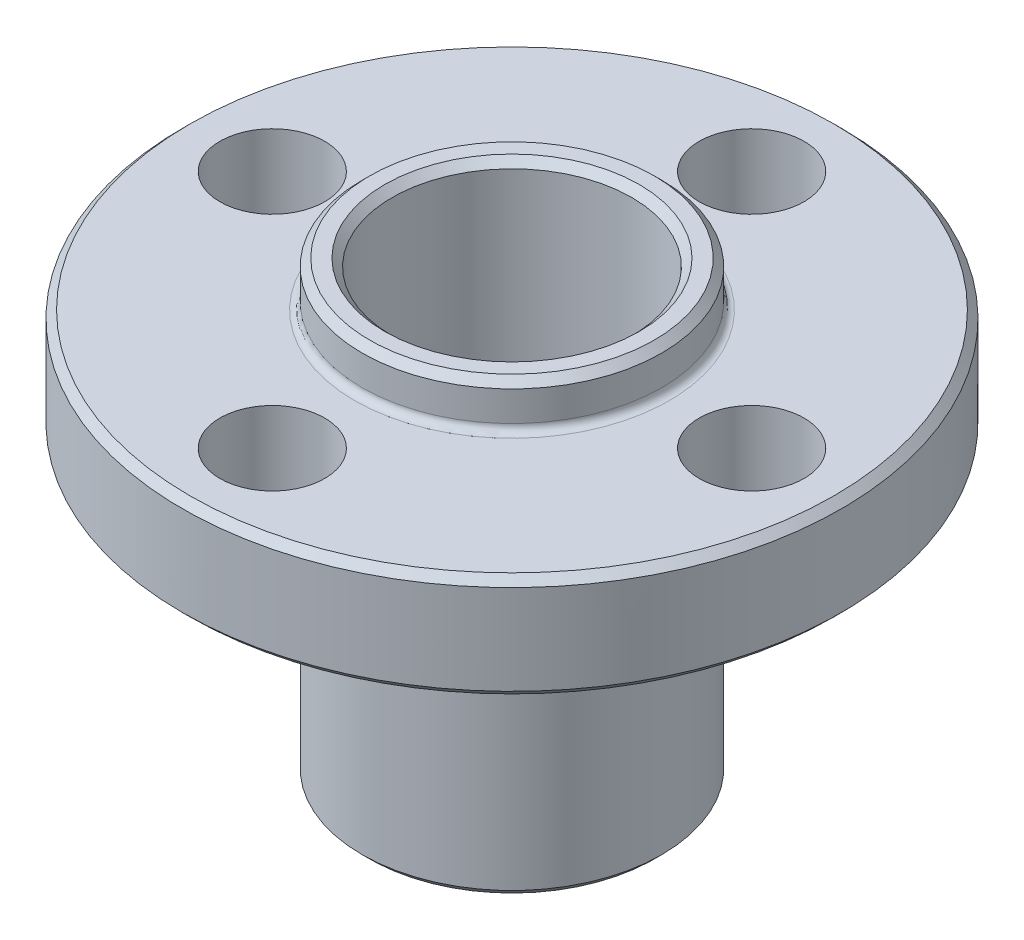
from build123d import *

# Parameters (mm, degrees)
SCHIZZO2_R               = 1.75
TAGLIO_ESTRUSIONE1_DEPTH = 10
SMUSSO1_SIZE             = 0.25
RACCORDO1_R              = 0.25


with BuildPart() as part:
    # Schizzo1 → Rivoluzione1 (revolve)
    with BuildSketch(Plane.XY):
        Polygon((0, 0), (0, 15), (1, 15), (1, 13.5), (7, 13.5), (7, 10), (1, 10), (1, 0), align=None)
    revolve(axis=Axis((-4, 0, 0), (0, 1, 0)))

    # Schizzo2 → Taglio-Estrusione1 (cut)
    with BuildSketch(Plane(origin=(0, 13.5, 0), x_dir=(1, 0, 0), z_dir=(0, 1, 0))):
        with Locations((-4, -8)):
            Circle(SCHIZZO2_R)
        with Locations((-12, 0)):
            Circle(SCHIZZO2_R)
        with Locations((-4, 8)):
            Circle(SCHIZZO2_R)
        with Locations((4, 0)):
            Circle(SCHIZZO2_R)
    extrude(amount=-TAGLIO_ESTRUSIONE1_DEPTH, mode=Mode.SUBTRACT)

    # Smusso1
    smusso1_edges = [part.edges().sort_by_distance(p)[0] for p in [
        (-15, 10, 0),
        (-9, 0, 0),
        (-8, 15, 0),
        (-9, 15, 0),
        (-15, 13.5, 0),
    ]]
    chamfer(smusso1_edges, length=SMUSSO1_SIZE)

    # Raccordo1
    raccordo1_edges = [part.edges().sort_by_distance(p)[0] for p in [
        (-9, 10, 0),
        (-9, 13.5, 0),
    ]]
    fillet(raccordo1_edges, radius=RACCORDO1_R)


solid = part.part
